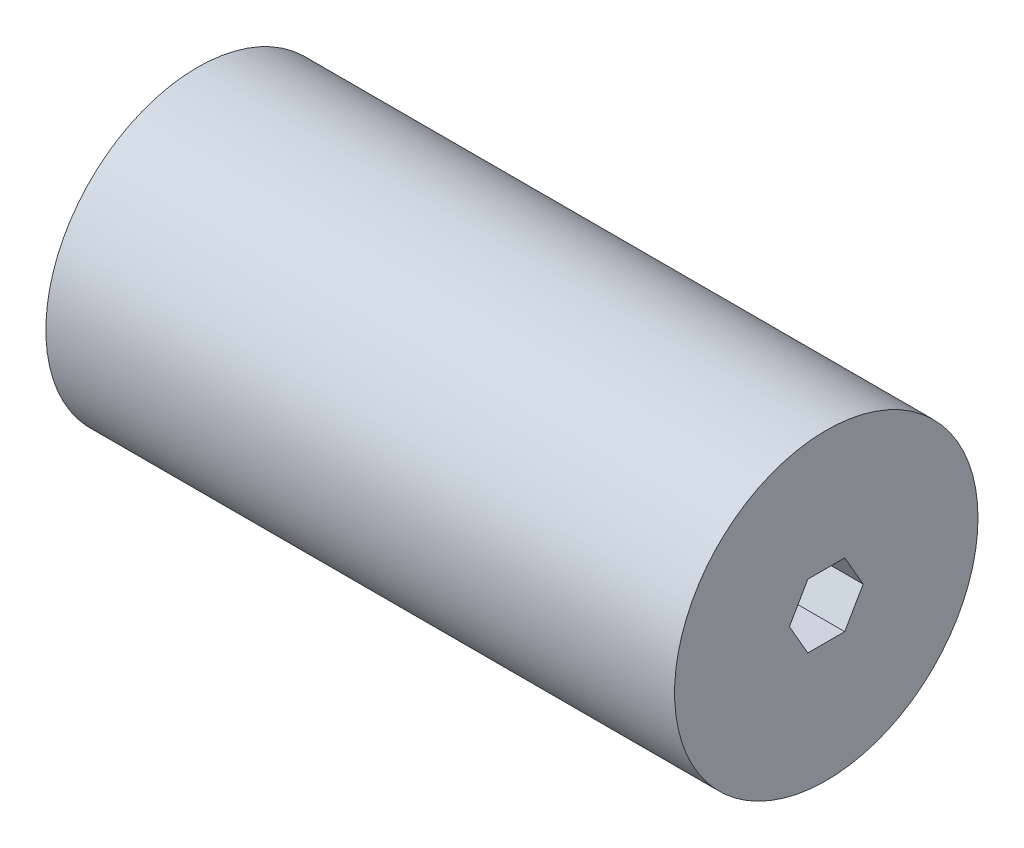
from build123d import *

# Parameters (mm, degrees)
SKETCH1_R           = 30.1625
BOSS_EXTRUDE1_DEPTH = 62.5


with BuildPart() as part:
    # Sketch1 → Boss-Extrude1 (new, symmetric)
    with BuildSketch(Plane(origin=(0, 0, 0), x_dir=(0, 0, -1), z_dir=(1, 0, 0))):
        Circle(SKETCH1_R)
        Polygon((7.332348419, 0), (3.666174209, 6.35), (-3.666174209, 6.35), (-7.332348419, 0), (-3.666174209, -6.35), (3.666174209, -6.35), align=None, mode=Mode.SUBTRACT)
    extrude(amount=BOSS_EXTRUDE1_DEPTH, both=True)


solid = part.part
